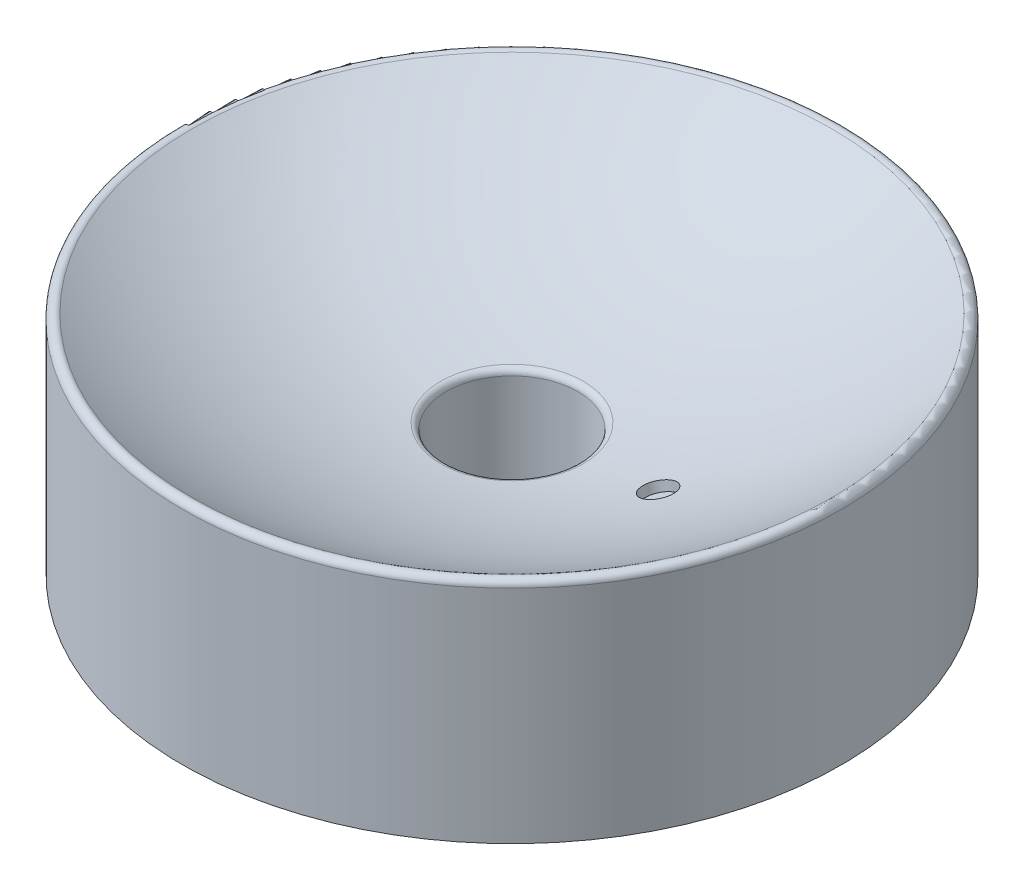
from build123d import *


with BuildPart() as part:
    # Skizze1 → Rotation1 (revolve)
    with BuildSketch(Plane.XY, mode=Mode.PRIVATE) as rotation1_sk:
        with BuildLine():
            Line((21, 40), (21, 0))
            Line((21, 0), (22.5, 0))
            Line((22.5, 0), (22.5, 30.992047723))
            ThreePointArc((22.5, 30.992047723), (22.750654736, 31.654227211), (23.376963351, 31.98444985))
            ThreePointArc((23.376963351, 31.98444985), (64.24040311, 41.730422057), (101.963350785, 60.217820521))
            ThreePointArc((101.963350785, 60.217820521), (102.981326701, 60.250556357), (103.5, 59.374015081))
            Line((103.5, 59.374015081), (103.5, 0))
            Line((103.5, 0), (105, 0))
            Line((105, 0), (105, 70.490862433))
            ThreePointArc((105, 70.490862433), (103.931735943, 72.260570921), (101.868131868, 72.13976344))
            ThreePointArc((101.868131868, 72.13976344), (64.106096115, 52.343326056), (22.747252747, 41.98396543))
            ThreePointArc((22.747252747, 41.98396543), (21.499084528, 41.321836884), (21, 40))
        make_face()
    revolve(rotation1_sk.sketch.rotate(Axis((0, 0, 0), (0, 1, 0)), 90), axis=Axis((0, 0, 0), (0, 1, 0)))  # turned: the seam where the file's is

    # Skizze3 → Schnitt-Rotation1 (revolve, cut)
    with BuildSketch(Plane.XY):
        Polygon((41.739821974, 45.447201272), (42.516279109, 42.549423793), (45.897019501, 43.455290451), (48.226390907, 34.761958014), (49.675279646, 35.150186582), (46.569451105, 46.741296497), align=None)
    revolve(axis=Axis((0, 220.540854102, 0), (0.258819045, -0.965925826, 0)), mode=Mode.SUBTRACT)


solid = part.part
